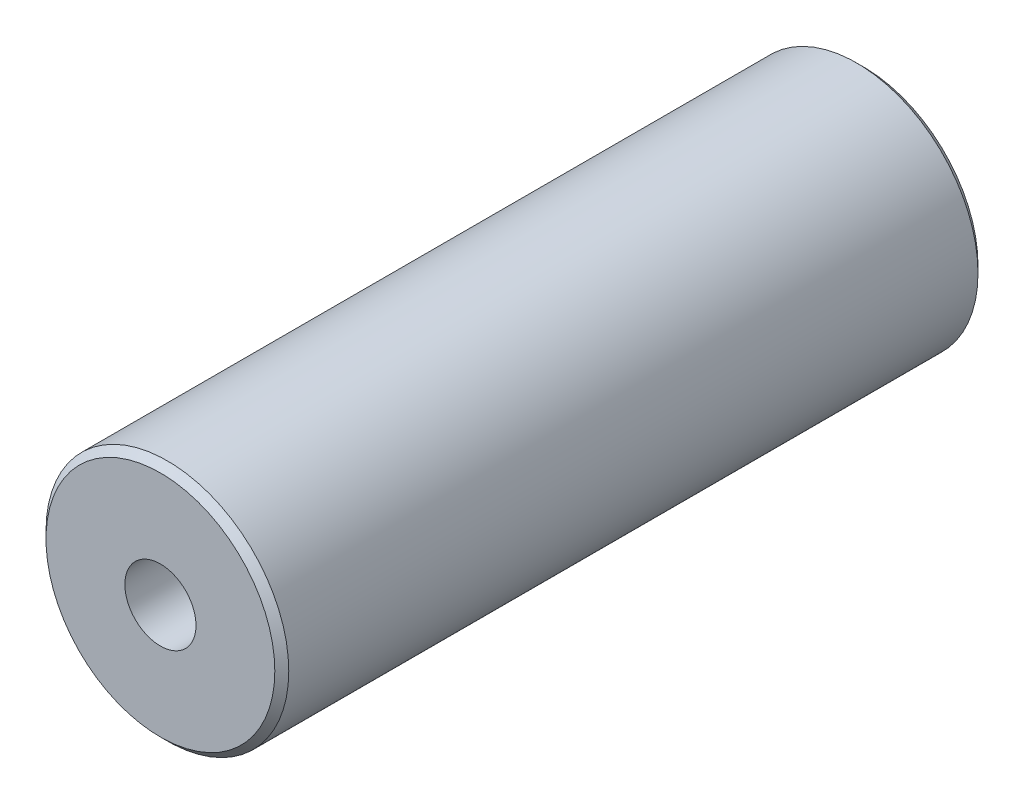
from build123d import *

# Parameters (mm, degrees)
SKETCH1_R                = 8.7
BASE_EXTRUDE_DEPTH       = 25.2
BASE_EXTRUDE_DEPTH_BACK  = 25.2
SKETCH2_R                = 8
STROKECHAMBER_DEPTH      = 15.2
STROKECHAMBER_DEPTH_BACK = 15.2
CHAMFER1_SIZE            = 0.5
SKETCH3_R                = 2.55
THRUBORE_DEPTH           = 26.2
SKETCH4_R                = 2.55
CUT_EXTRUDE1_DEPTH       = 51.4


with BuildPart() as part:
    # Sketch1 → Base-Extrude (new body, two sides)
    with BuildSketch(Plane.XY) as base_extrude_sk:
        Circle(SKETCH1_R)
    extrude(amount=BASE_EXTRUDE_DEPTH)
    extrude(base_extrude_sk.sketch, amount=-BASE_EXTRUDE_DEPTH_BACK)

    # Sketch2 → StrokeChamber (cut, two sides)
    with BuildSketch(Plane.XY) as strokechamber_sk:
        Circle(SKETCH2_R)
    extrude(amount=STROKECHAMBER_DEPTH, mode=Mode.SUBTRACT)
    extrude(strokechamber_sk.sketch, amount=-STROKECHAMBER_DEPTH_BACK, mode=Mode.SUBTRACT)

    # Chamfer1
    chamfer1_edges = [part.edges().sort_by_distance(p)[0] for p in [
        (-8.7, 0, 25.2),
        (-8.7, 0, -25.2),
    ]]
    chamfer(chamfer1_edges, length=CHAMFER1_SIZE)

    # Sketch3 → Thrubore (cut, through all)
    with BuildSketch(Plane.XY):
        Circle(SKETCH3_R)
    extrude(amount=THRUBORE_DEPTH, mode=Mode.SUBTRACT)

    # Sketch4 → Cut-Extrude1 (cut, through all)
    with BuildSketch(Plane.XY.offset(25.2)):
        Circle(SKETCH4_R)
    extrude(amount=-CUT_EXTRUDE1_DEPTH, mode=Mode.SUBTRACT)


solid = part.part
